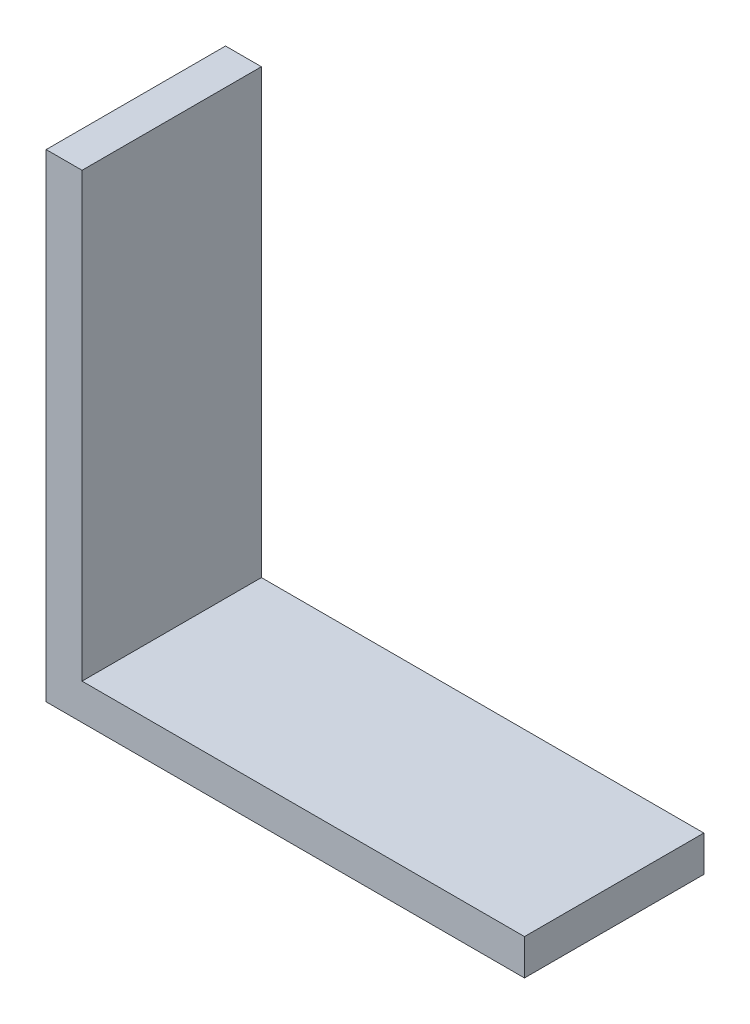
from build123d import *

# Parameters (mm, degrees)
SKETCH1_W           = 40
SKETCH1_H           = 15
BOSS_EXTRUDE1_DEPTH = 3
SKETCH2_W           = 3
SKETCH2_H           = 15
BOSS_EXTRUDE2_DEPTH = 37


with BuildPart() as part:
    # Sketch1 → Boss-Extrude1 (new body)
    with BuildSketch(Plane(origin=(0, 0, 0), x_dir=(1, 0, 0), z_dir=(0, 1, 0))):
        with Locations((20, 7.5)):
            Rectangle(SKETCH1_W, SKETCH1_H)
    extrude(amount=BOSS_EXTRUDE1_DEPTH)

    # Sketch2 → Boss-Extrude2 (add)
    with BuildSketch(Plane(origin=(0, 3, 0), x_dir=(1, 0, 0), z_dir=(0, 1, 0))):
        with Locations((1.5, 7.5)):
            Rectangle(SKETCH2_W, SKETCH2_H)
    extrude(amount=BOSS_EXTRUDE2_DEPTH)


solid = part.part
